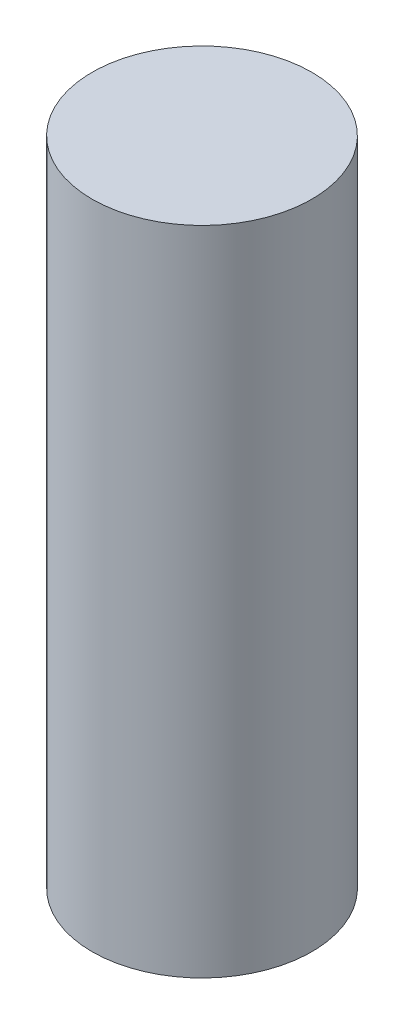
from build123d import *

# Parameters (mm, degrees)
SKETCH1_R           = 7.085
BOSS_EXTRUDE1_DEPTH = 42.0116


with BuildPart() as part:
    # Sketch1 → Boss-Extrude1 (new body)
    with BuildSketch(Plane(origin=(0, 0, 0), x_dir=(1, 0, 0), z_dir=(0, 1, 0))):
        Circle(SKETCH1_R)
    extrude(amount=BOSS_EXTRUDE1_DEPTH)


solid = part.part
